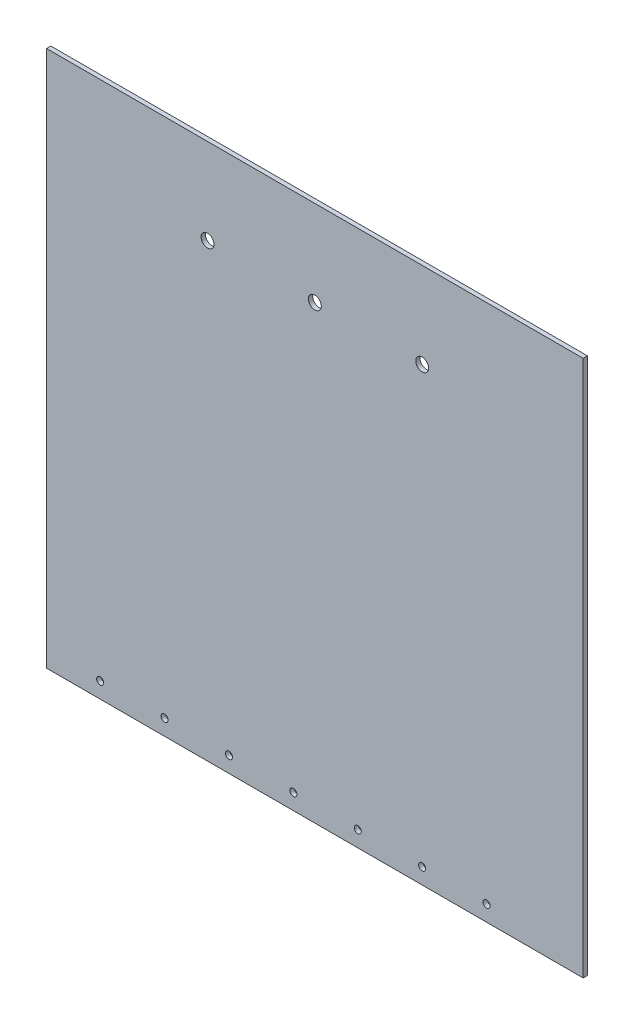
from build123d import *

# Parameters (mm, degrees)
SKIZZE1_W                       = 250
SKIZZE1_H                       = 250
AUFSATZ_LINEAR_AUSTRAGEN1_DEPTH = 2
SKIZZE2_R                       = 3
SCHNITT_LINEAR_AUSTRAGEN1_DEPTH = 3
M4_GEWINDEBOHRUNG1_D            = 3.3


with BuildPart() as part:
    # Skizze1 → Aufsatz-Linear austragen1 (new body)
    with BuildSketch(Plane.XY):
        Rectangle(SKIZZE1_W, SKIZZE1_H)
    extrude(amount=AUFSATZ_LINEAR_AUSTRAGEN1_DEPTH)

    # Skizze2 → Schnitt-Linear austragen1 (cut, through all)
    with BuildSketch(Plane.XY.offset(2)):
        with Locations((0, 85)):
            Circle(SKIZZE2_R)
        with Locations((-50, 85)):
            Circle(SKIZZE2_R)
        with Locations((50, 85)):
            Circle(SKIZZE2_R)
    extrude(amount=-SCHNITT_LINEAR_AUSTRAGEN1_DEPTH, mode=Mode.SUBTRACT)

    # M4 Gewindebohrung1 (through all)
    with Locations(Plane(origin=(0, 0, 0), x_dir=(-1, 0, 0), z_dir=(0, 0, -1))):
        with Locations((-80, -117.64), (-50, -117.64), (-20, -117.64), (10, -117.64), (40, -117.64), (70, -117.64), (100, -117.64)):
            Hole(M4_GEWINDEBOHRUNG1_D / 2)


solid = part.part
